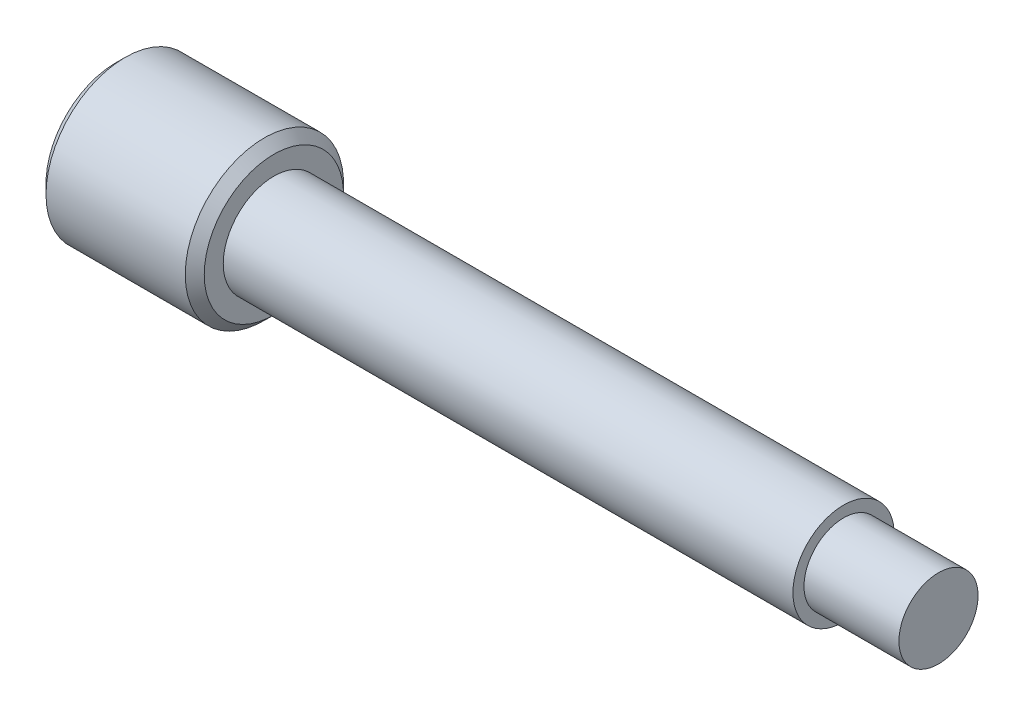
from build123d import *

# Parameters (mm, degrees)
CHAMFER1_SIZE = 0.3


with BuildPart() as part:
    # Sketch2 → Revolve1 (revolve)
    with BuildSketch(Plane(origin=(0, 0, 0), x_dir=(1, 0, 0), z_dir=(0, 1, 0))):
        Polygon((-16.496503497, 2.5), (-11.496503497, 2.5), (-11.496503497, 1.6), (6.503496503, 1.6), (6.503496503, 1.25), (9.503496503, 1.25), (9.503496503, 0), (-16.496503497, 0), align=None)
    revolve(axis=Axis((-6.153846154, 0, 0), (1, 0, 0)))

    # Chamfer1
    chamfer1_edges = [part.edges().sort_by_distance(p)[0] for p in [
        (-16.496503497, 0, 2.5),
        (-11.496503497, 0, 2.5),
    ]]
    chamfer(chamfer1_edges, length=CHAMFER1_SIZE)


solid = part.part
